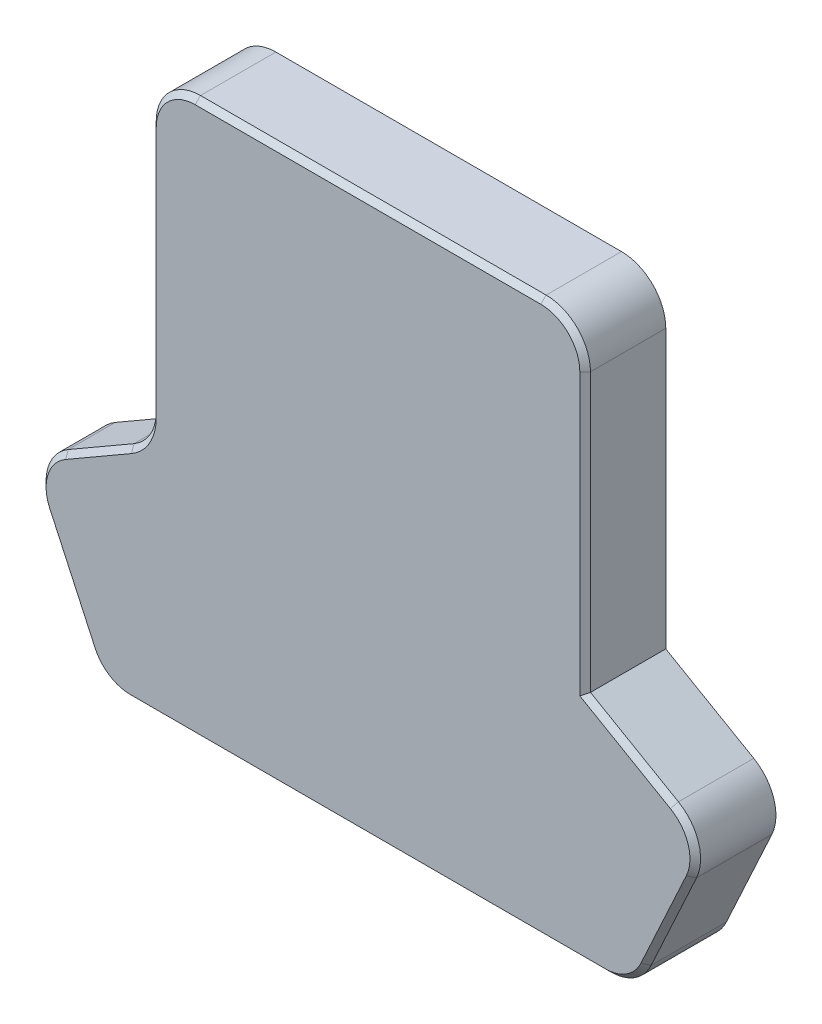
from build123d import *

# Parameters (mm, degrees)
BOSS_EXTRUDE1_DEPTH = 3.2
SKETCH2_W           = 20
SKETCH2_H           = 28
BOSS_EXTRUDE2_DEPTH = 4.9
BOSS_EXTRUDE3_DEPTH = 1
FILLET1_R           = 5
CHAMFER1_SIZE       = 0.6


with BuildPart() as part:
    # Sketch1 → Boss-Extrude1 (new body)
    with BuildSketch(Plane.XY):
        Polygon((-54.5, 42.45), (-12.4, 42.45), (-12.4, 7.25), (-63.3440625, 7.25), (-60, 0), (0, 0), (8.376844495, 18.161180477), (-5.5, 26.172980381), (-5.5, 62.5), (-54.5, 62.5), align=None)
    extrude(amount=BOSS_EXTRUDE1_DEPTH)

    # Sketch2 → Boss-Extrude2 (add)
    with BuildSketch(Plane.XY.offset(3.2)):
        Polygon((-5.5, 26.172980381), (-5.5, 62.5), (-54.5, 62.5), (-54.5, 26.172980381), (-68.376844495, 18.161180477), (-60, 0), (0, 0), (8.376844495, 18.161180477), align=None)
        with Locations((-25.5, 24.85)):
            Rectangle(SKETCH2_W, SKETCH2_H, mode=Mode.SUBTRACT)
    extrude(amount=BOSS_EXTRUDE2_DEPTH)

    # Sketch3 → Boss-Extrude3 (add)
    with BuildSketch(Plane.XY.offset(8.1)):
        Polygon((-68.376844495, 18.161180477), (-60, 0), (0, 0), (8.376844495, 18.161180477), (-5.5, 26.172980381), (-5.5, 62.5), (-54.5, 62.5), (-54.5, 26.172980381), align=None)
    extrude(amount=BOSS_EXTRUDE3_DEPTH)

    # Fillet1
    fillet1_edges = [part.edges().sort_by_distance(p)[0] for p in [
        (-60, 0, 4.55),
        (-54.5, 26.172980381, 6.15),
        (-68.376844495, 18.161180477, 6.15),
        (0, 0, 4.55),
        (8.376844495, 18.161180477, 4.55),
        (-5.5, 62.5, 4.55),
        (-54.5, 62.5, 4.55),
    ]]
    fillet(fillet1_edges, radius=FILLET1_R)

    # Chamfer1
    chamfer1_edges = [part.edges().sort_by_distance(p)[0] for p in [
        (-55.169872981, 26.559731727, 9.1),
        (-5.5, 41.836490191, 9.1),
        (-0.537219377, 23.307717653, 9.1),
        (3.903075742, 8.461952829, 9.1),
        (-60.712780623, 22.586029816, 9.1),
        (-63.903075742, 8.461952829, 9.1),
        (-30, 0, 9.1),
        (-30, 62.5, 9.1),
        (-54.5, 43.279865864, 9.1),
        (-53.035533906, 61.035533906, 9.1),
        (-6.964466094, 61.035533906, 9.1),
        (-66.691006554, 17.625777943, 9.1),
        (-59.495268482, 0.788642997, 9.1),
        (-0.504731518, 0.788642997, 9.1),
        (6.691006554, 17.625777943, 9.1),
    ]]
    chamfer(chamfer1_edges, length=CHAMFER1_SIZE)


solid = part.part
